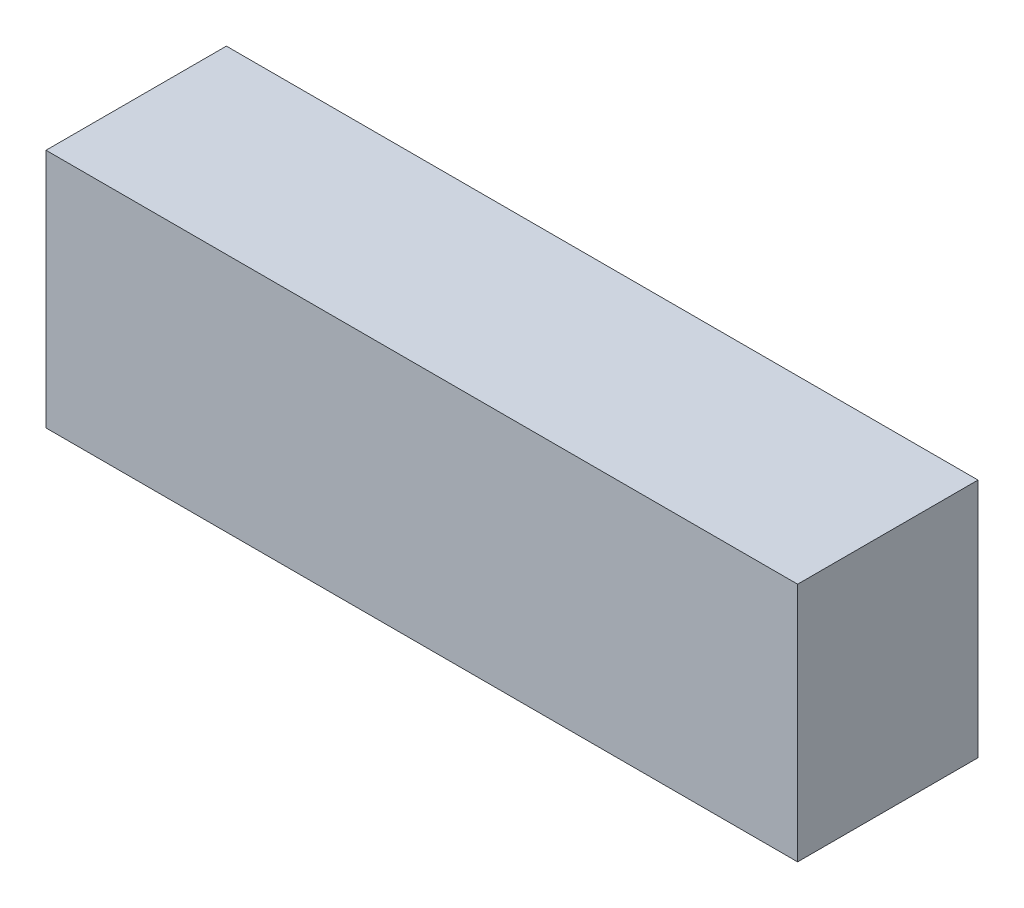
from build123d import *

# Parameters (mm, degrees)
SKETCH1_W           = 635
SKETCH1_H           = 152.4
BOSS_EXTRUDE1_DEPTH = 203.2


with BuildPart() as part:
    # Sketch1 → Boss-Extrude1 (new body)
    with BuildSketch(Plane(origin=(0, 0, 0), x_dir=(1, 0, 0), z_dir=(0, 1, 0))):
        Rectangle(SKETCH1_W, SKETCH1_H)
    extrude(amount=BOSS_EXTRUDE1_DEPTH)


solid = part.part
